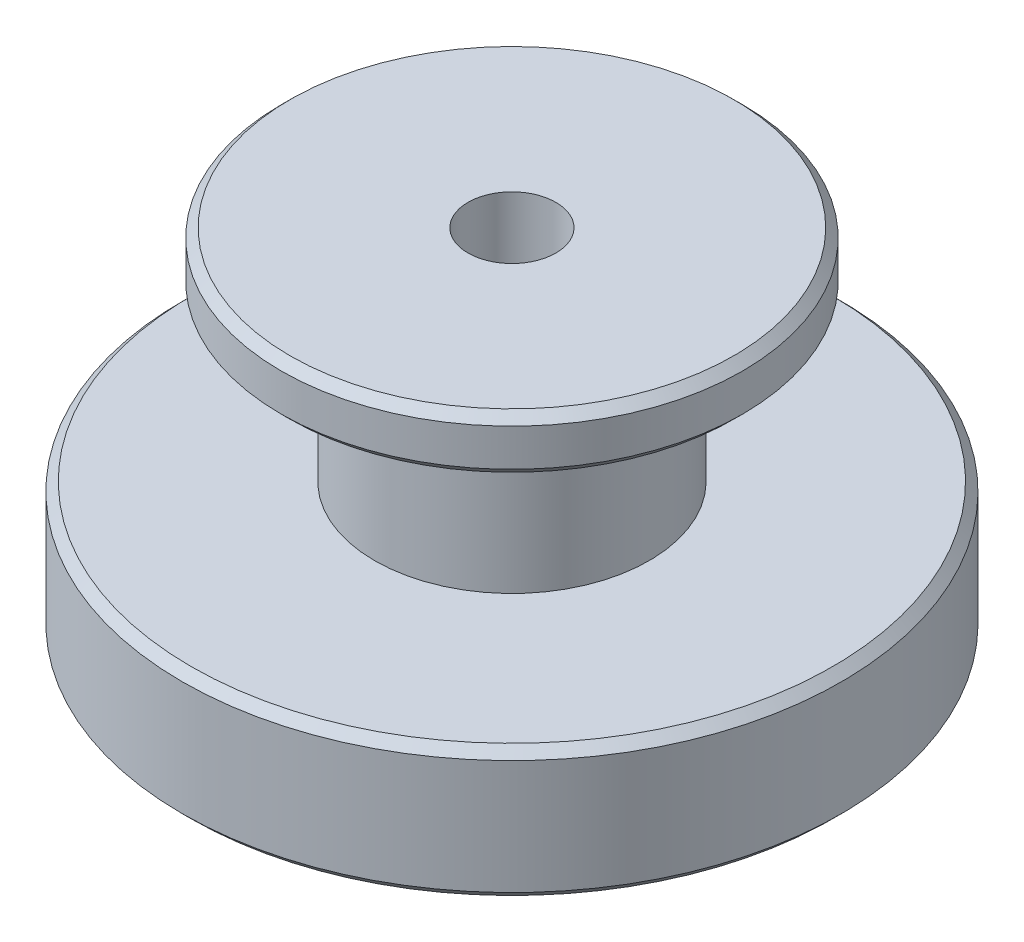
from build123d import *


with BuildPart() as part:
    # Croquis1 → Revolución1 (revolve)
    with BuildSketch(Plane.XY):
        Polygon((4, 0), (29.2, 0), (30, 0.8), (30, 11.2), (29.2, 12), (12.5, 12), (12.5, 27), (20.2, 27), (21, 27.8), (21, 31.2), (20.2, 32), (4, 32), align=None)
    revolve(axis=Axis((0, 175.803710109, 0), (0, -1, 0)))


solid = part.part
